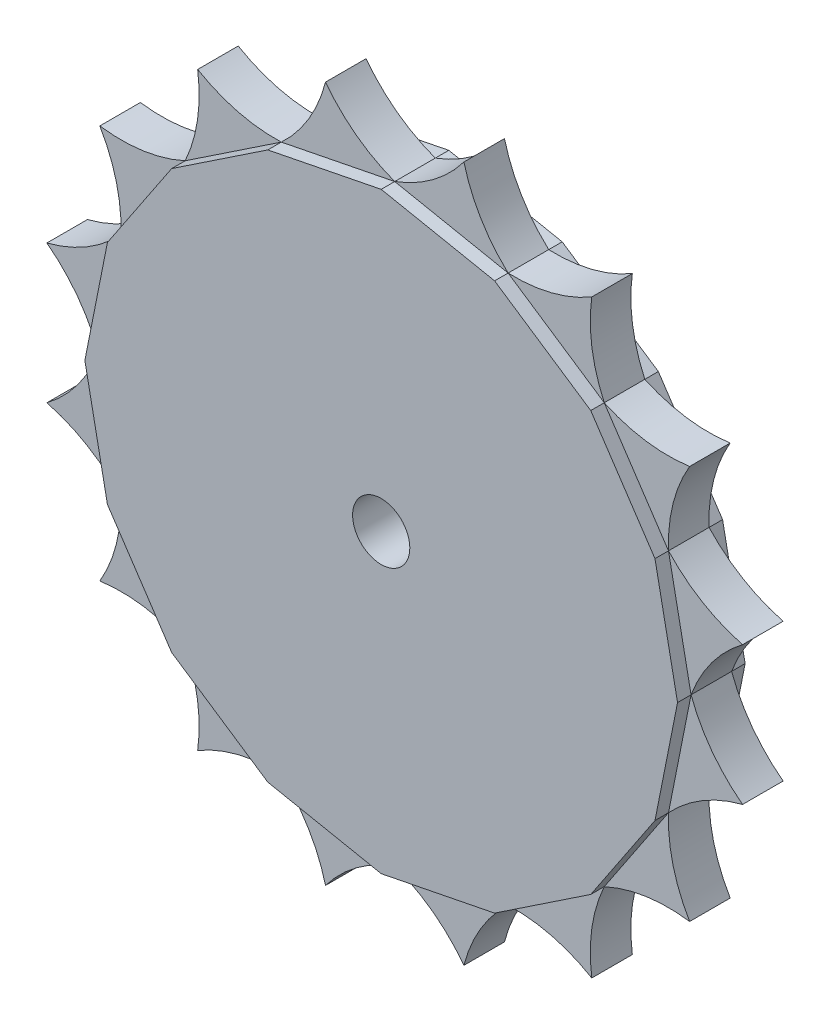
from build123d import *

# Parameters (mm, degrees)
Y_KSEKLIK_EKSTR_ZYON1_DEPTH = 2.5
IZIM3_R                     = 2.116464506
KES_EKSTR_ZYON2_DEPTH       = 31
Y_KSEKLIK_EKSTR_ZYON3_DEPTH = 1.5


with BuildPart() as part:
    # Çizim1 → Yükseklik-Ekstrüzyon1 (new body, symmetric)
    with BuildSketch(Plane.XY):
        Polygon((20.082496858, 0), (18.413844112, 8.388883847), (13.661923129, 15.500636173), (6.550170803, 20.252557156), (-1.838713044, 21.921209901), (-10.22759689, 20.252557156), (-17.339349217, 15.500636173), (-22.0912702, 8.388883847), (-23.759922945, 0), (-22.0912702, -8.388883847), (-17.339349217, -15.500636173), (-10.22759689, -20.252557156), (-1.838713044, -21.921209901), (6.550170803, -20.252557156), (13.661923129, -15.500636173), (18.413844112, -8.388883847), align=None)
    extrude(amount=Y_KSEKLIK_EKSTR_ZYON1_DEPTH, both=True)

    # Çizim3 → Kes-Ekstrüzyon2 (cut)
    with BuildSketch(Plane(origin=(0, 0, -2.5), x_dir=(-1, 0, 0), z_dir=(0, 0, -1))):
        with Locations((1.838713044, 0)):
            Circle(IZIM3_R)
    extrude(amount=-KES_EKSTR_ZYON2_DEPTH, mode=Mode.SUBTRACT)

    # Çizim6 → Yükseklik-Ekstrüzyon3 (add, symmetric)
    with BuildSketch(Plane.XY):
        with BuildLine():
            ThreePointArc((-6.957303461, 25.732891749), (-4.672314924, 23.458692825), (-1.838713044, 21.921209901))
            Line((-1.838713044, 21.921209901), (-10.22759689, 20.252557156))
            ThreePointArc((-10.22759689, 20.252557156), (-8.198059352, 22.757378654), (-6.957303461, 25.732891749))
        make_face()
        with BuildLine():
            ThreePointArc((3.279877374, 25.732891749), (4.520633265, 22.757378654), (6.550170803, 20.252557156))
            Line((6.550170803, 20.252557156), (-1.838713044, 21.921209901))
            ThreePointArc((-1.838713044, 21.921209901), (0.994888837, 23.458692825), (3.279877374, 25.732891749))
        make_face()
        with BuildLine():
            ThreePointArc((12.737799217, 21.815292249), (12.745428626, 18.591459879), (13.661923129, 15.500636173))
            Line((13.661923129, 15.500636173), (6.550170803, 20.252557156))
            ThreePointArc((6.550170803, 20.252557156), (9.756446826, 20.588633667), (12.737799217, 21.815292249))
        make_face()
        with BuildLine():
            ThreePointArc((19.976579206, 14.576512261), (18.749920623, 11.59515987), (18.413844112, 8.388883847))
            Line((18.413844112, 8.388883847), (13.661923129, 15.500636173))
            ThreePointArc((13.661923129, 15.500636173), (16.752746836, 14.584141669), (19.976579206, 14.576512261))
        make_face()
        with BuildLine():
            ThreePointArc((23.894178705, 5.118590417), (21.619979781, 2.833601881), (20.082496858, 0))
            Line((20.082496858, 0), (18.413844112, 8.388883847))
            ThreePointArc((18.413844112, 8.388883847), (20.91866561, 6.359346308), (23.894178705, 5.118590417))
        make_face()
        with BuildLine():
            ThreePointArc((23.894178705, -5.118590417), (20.91866561, -6.359346308), (18.413844112, -8.388883847))
            Line((18.413844112, -8.388883847), (20.082496858, 0))
            ThreePointArc((20.082496858, 0), (21.619979781, -2.833601881), (23.894178705, -5.118590417))
        make_face()
        with BuildLine():
            ThreePointArc((19.976579206, -14.576512261), (16.752746836, -14.584141669), (13.661923129, -15.500636173))
            Line((13.661923129, -15.500636173), (18.413844112, -8.388883847))
            ThreePointArc((18.413844112, -8.388883847), (18.749920623, -11.59515987), (19.976579206, -14.576512261))
        make_face()
        with BuildLine():
            ThreePointArc((12.737799217, -21.815292249), (9.756446826, -20.588633667), (6.550170803, -20.252557156))
            Line((6.550170803, -20.252557156), (13.661923129, -15.500636173))
            ThreePointArc((13.661923129, -15.500636173), (12.745428626, -18.591459879), (12.737799217, -21.815292249))
        make_face()
        with BuildLine():
            ThreePointArc((3.279877374, -25.732891749), (0.994888837, -23.458692825), (-1.838713044, -21.921209901))
            Line((-1.838713044, -21.921209901), (6.550170803, -20.252557156))
            ThreePointArc((6.550170803, -20.252557156), (4.520633265, -22.757378654), (3.279877374, -25.732891749))
        make_face()
        with BuildLine():
            ThreePointArc((-6.957303461, -25.732891749), (-8.198059352, -22.757378654), (-10.22759689, -20.252557156))
            Line((-10.22759689, -20.252557156), (-1.838713044, -21.921209901))
            ThreePointArc((-1.838713044, -21.921209901), (-4.672314924, -23.458692825), (-6.957303461, -25.732891749))
        make_face()
        with BuildLine():
            ThreePointArc((-16.415225305, -21.815292249), (-16.422854713, -18.591459879), (-17.339349217, -15.500636173))
            Line((-17.339349217, -15.500636173), (-10.22759689, -20.252557156))
            ThreePointArc((-10.22759689, -20.252557156), (-13.433872913, -20.588633667), (-16.415225305, -21.815292249))
        make_face()
        with BuildLine():
            ThreePointArc((-23.654005293, -14.576512261), (-22.427346711, -11.59515987), (-22.0912702, -8.388883847))
            Line((-22.0912702, -8.388883847), (-17.339349217, -15.500636173))
            ThreePointArc((-17.339349217, -15.500636173), (-20.430172923, -14.584141669), (-23.654005293, -14.576512261))
        make_face()
        with BuildLine():
            ThreePointArc((-27.571604792, -5.118590417), (-25.297405869, -2.833601881), (-23.759922945, 0))
            Line((-23.759922945, 0), (-22.0912702, -8.388883847))
            ThreePointArc((-22.0912702, -8.388883847), (-24.596091698, -6.359346308), (-27.571604792, -5.118590417))
        make_face()
        with BuildLine():
            ThreePointArc((-27.571604793, 5.118590417), (-24.596091698, 6.359346308), (-22.0912702, 8.388883847))
            Line((-22.0912702, 8.388883847), (-23.759922945, 0))
            ThreePointArc((-23.759922945, 0), (-25.297405869, 2.833601881), (-27.571604793, 5.118590417))
        make_face()
        with BuildLine():
            ThreePointArc((-23.654005293, 14.576512261), (-20.430172923, 14.584141669), (-17.339349217, 15.500636173))
            Line((-17.339349217, 15.500636173), (-22.0912702, 8.388883847))
            ThreePointArc((-22.0912702, 8.388883847), (-22.427346711, 11.59515987), (-23.654005293, 14.576512261))
        make_face()
        with BuildLine():
            ThreePointArc((-16.415225305, 21.815292249), (-13.433872913, 20.588633667), (-10.22759689, 20.252557156))
            Line((-10.22759689, 20.252557156), (-17.339349217, 15.500636173))
            ThreePointArc((-17.339349217, 15.500636173), (-16.422854713, 18.591459879), (-16.415225305, 21.815292249))
        make_face()
    extrude(amount=Y_KSEKLIK_EKSTR_ZYON3_DEPTH, both=True)


solid = part.part
